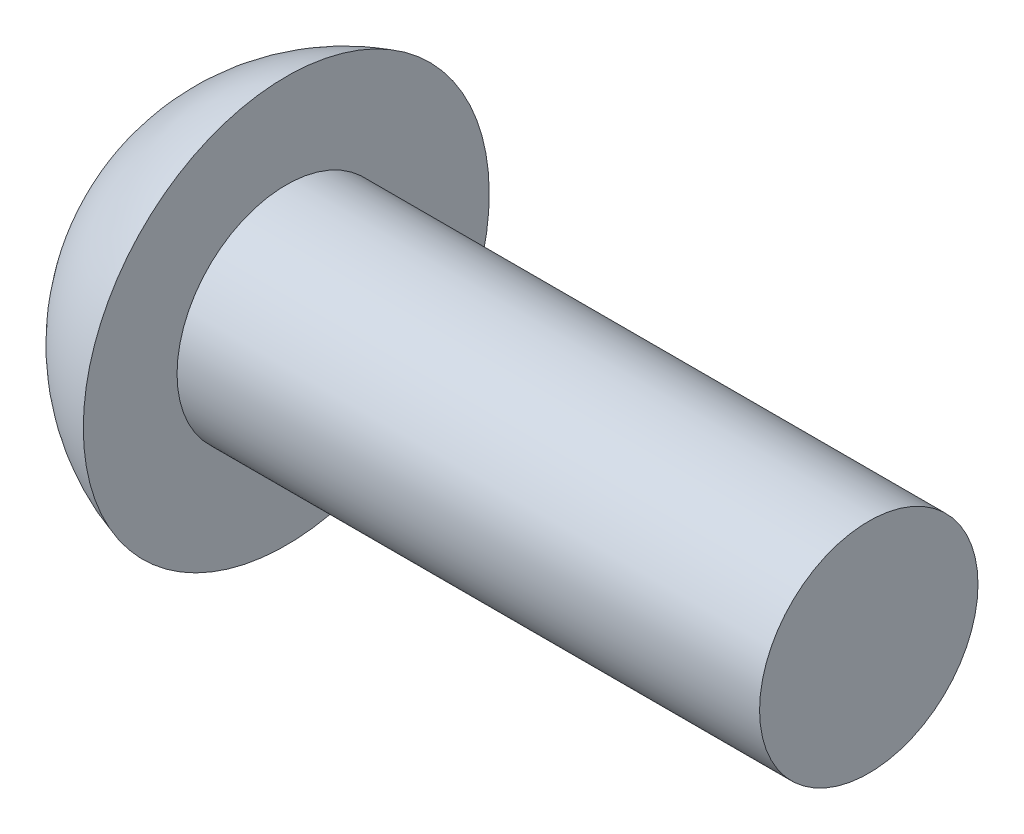
from build123d import *

# Parameters (mm, degrees)
SKETCH3_W    = 0.53
SKETCH3_H    = 3
SKETCH4_W    = 0.53
SKETCH4_H    = 1.304822816
RECPAT_COUNT = 2
RECPAT_ANGLE = 90


with BuildPart() as part:
    # BodySke → Base-Revolve (revolve)
    with BuildSketch(Plane.XY):
        with BuildLine():
            Line((2.1, 1.5), (2.1, 2.787471973))
            ThreePointArc((2.1, 2.787471973), (0.583753036, 1.744992837), (0, 0))
            Line((0, 0), (10.1, 0))
            Line((10.1, 0), (10.1, 1.5))
            Line((10.1, 1.5), (2.1, 1.5))
        make_face()
    revolve(axis=Axis((-25.4, 0, 0), (1, 0, 0)))

    # Sketch3 → Recess section 0
    with BuildSketch(Plane(origin=(0, 0, 0), x_dir=(0, 0, -1), z_dir=(1, 0, 0))):
        Rectangle(SKETCH3_W, SKETCH3_H)
    # Sketch4 → Recess section 1
    with BuildSketch(Plane(origin=(1.7, 0, 0), x_dir=(0, 0, -1), z_dir=(1, 0, 0))):
        Rectangle(SKETCH4_W, SKETCH4_H)
    recess = loft(mode=Mode.SUBTRACT)

    # RecPat: Recess ×2 about axis
    recpat_axis = Axis((0, 0, 0), (1, 0, 0))
    for i in range(1, RECPAT_COUNT):
        add(recess.rotate(recpat_axis, i * RECPAT_ANGLE / (RECPAT_COUNT - 1)), mode=Mode.SUBTRACT)

    # RecCorSke → RecessCore (revolve, cut)
    with BuildSketch(Plane.XY):
        Polygon((0, 0), (0, 0.67487558), (1.7, 0.556), (1.880655351, 0), align=None)
    revolve(axis=Axis((-3.175, 0, 0), (1, 0, 0)), mode=Mode.SUBTRACT)


solid = part.part
